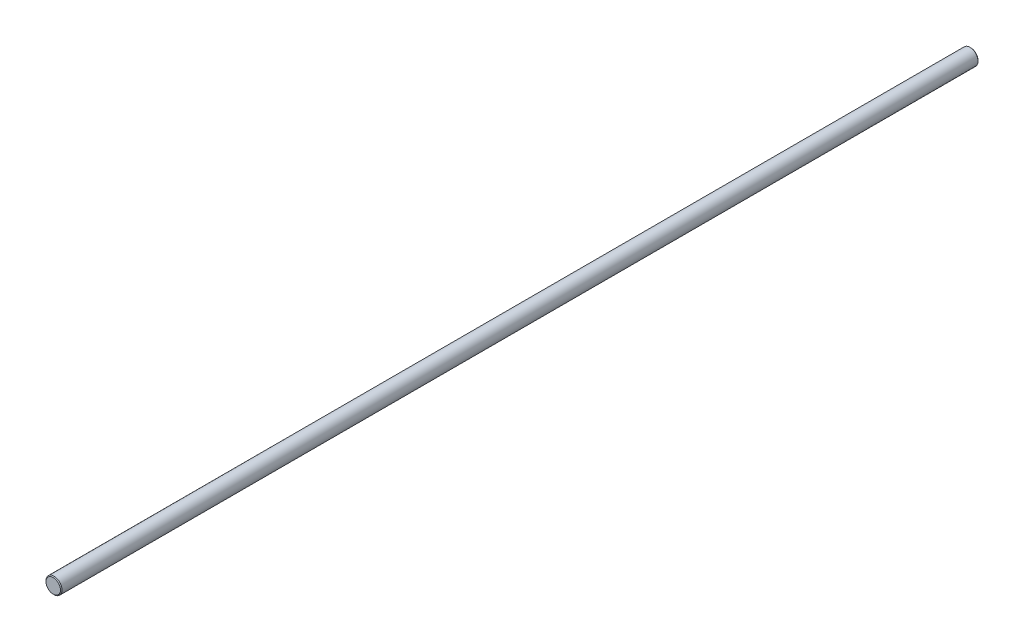
from build123d import *

# Parameters (mm, degrees)
SKETCH1_R      = 4
EXTRUDE1_DEPTH = 228.6
CHAMFER1_SIZE  = 0.4


with BuildPart() as part:
    # Sketch1 → Extrude1 (new body, symmetric)
    with BuildSketch(Plane.XY):
        Circle(SKETCH1_R)
    extrude(amount=EXTRUDE1_DEPTH, both=True)

    # Chamfer1
    chamfer1_edges = [part.edges().sort_by_distance(p)[0] for p in [
        (-4, 0, -228.6),
        (-4, 0, 228.6),
    ]]
    chamfer(chamfer1_edges, length=CHAMFER1_SIZE)


solid = part.part
